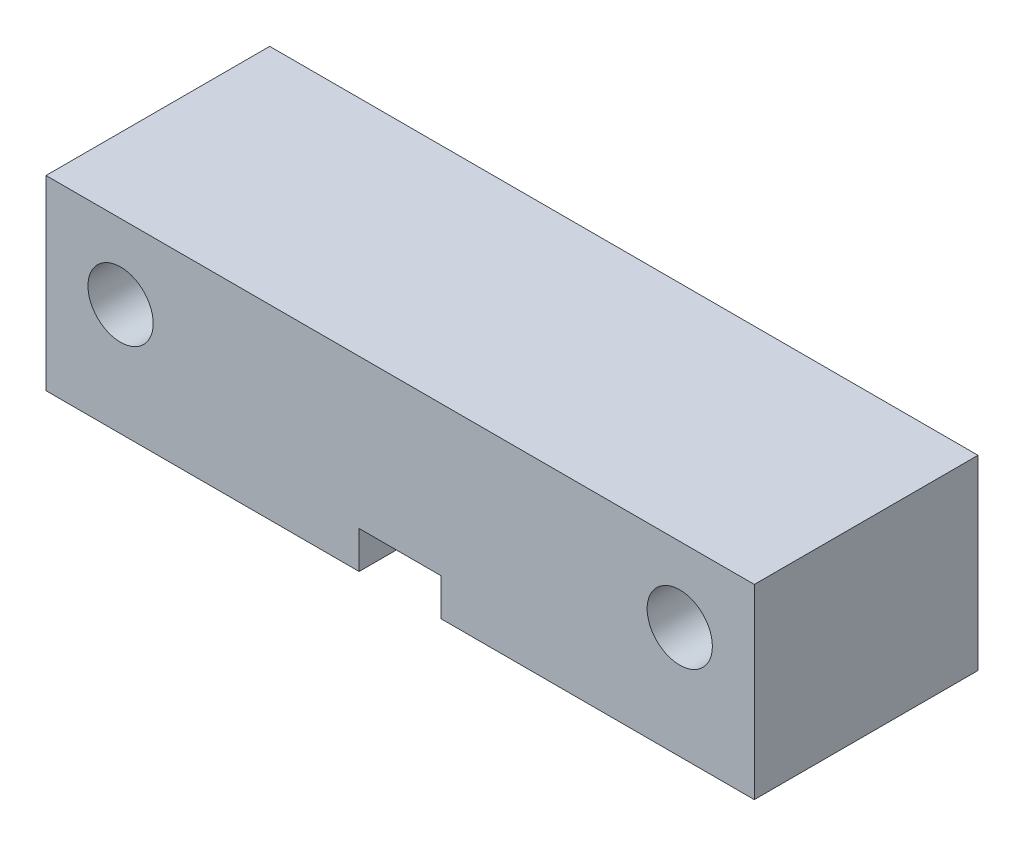
from build123d import *

# Parameters (mm, degrees)
SKETCH1_W           = 38
SKETCH1_H           = 10
SKETCH1_R           = 1.75
BOSS_EXTRUDE1_DEPTH = 12
CUT_EXTRUDE3_DEPTH  = 2


with BuildPart() as part:
    # Sketch1 → Boss-Extrude1 (new body)
    with BuildSketch(Plane.XY):
        Rectangle(SKETCH1_W, SKETCH1_H)
        with Locations((15, 1)):
            Circle(SKETCH1_R, mode=Mode.SUBTRACT)
        with Locations((-15, 1)):
            Circle(SKETCH1_R, mode=Mode.SUBTRACT)
    extrude(amount=BOSS_EXTRUDE1_DEPTH)

    # Sketch2 → Cut-Extrude3 (cut)
    with BuildSketch(Plane.XZ.offset(5)):
        with BuildLine():
            Line((2.2, -0.05), (2.2, 2.831644402))
            Line((2.2, 2.831644402), (14.549818203, 4.211125302))
            ThreePointArc((14.549818203, 4.211125302), (16.15, 6), (14.549818203, 7.788874698))
            Line((14.549818203, 7.788874698), (2.2, 9.168355598))
            Line((2.2, 9.168355598), (2.2, 12.75))
            ThreePointArc((2.2, 12.75), (0, 14.95), (-2.2, 12.75))
            Line((-2.2, 12.75), (-2.2, 9.713852446))
            Line((-2.2, 9.713852446), (-17.179844816, 7.785265067))
            ThreePointArc((-17.179844816, 7.785265067), (-18.75, 6), (-17.179844816, 4.214734933))
            Line((-17.179844816, 4.214734933), (-2.2, 2.286147554))
            Line((-2.2, 2.286147554), (-2.2, -0.05))
            ThreePointArc((-2.2, -0.05), (0, -2.25), (2.2, -0.05))
        make_face()
    extrude(amount=-CUT_EXTRUDE3_DEPTH, mode=Mode.SUBTRACT)


solid = part.part
